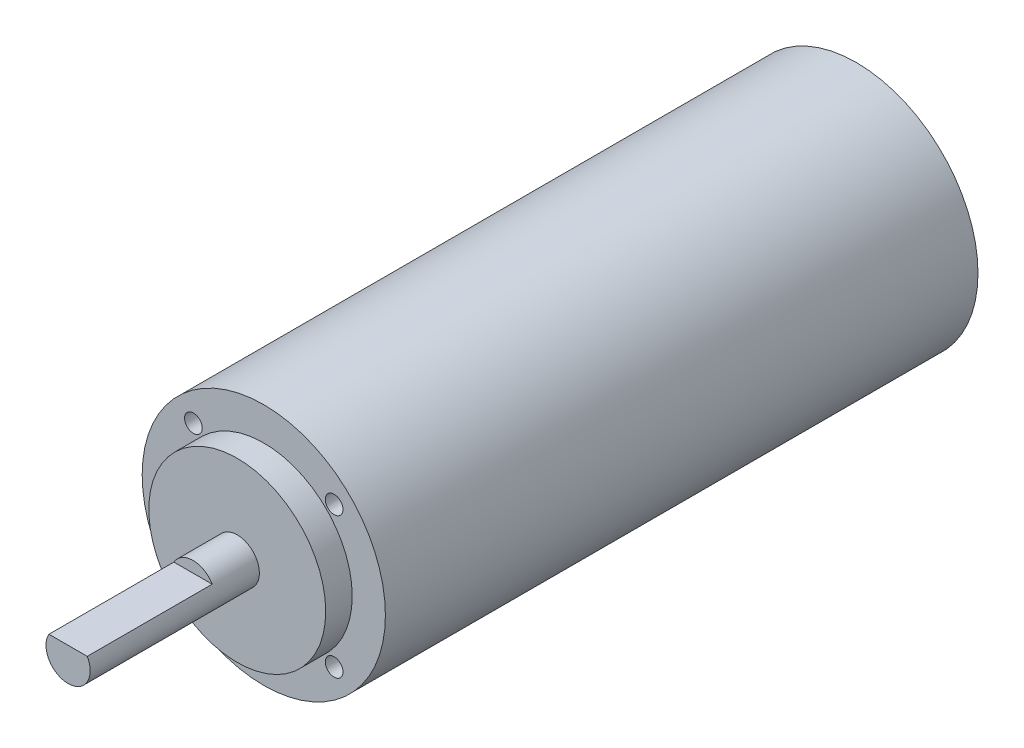
from build123d import *

# Parameters (mm, degrees)
CUT_EXTRUDE1_DEPTH              = 11.3
TAP_DRILL_FOR_M2X0_4_TAP1_D     = 1.6
TAP_DRILL_FOR_M2X0_4_TAP1_DEPTH = 4
TAP_DRILL_FOR_M2X0_4_TAP1_TIP   = 0.480688495


with BuildPart() as part:
    # Sketch4 → Revolve1 (revolve)
    with BuildSketch(Plane(origin=(0, 0, 0), x_dir=(0, 0, -1), z_dir=(1, 0, 0))):
        Polygon((0, 8), (0, 11), (21.4, 11), (53.6, 11), (53.6, 0), (0, 0), (-17.7, 0), (-17.7, 2), (-2.4, 2), (-2.4, 8), align=None)
    revolve(axis=Axis((0, 0, 0), (0, 0, -1)))

    # Sketch5 → Cut-Extrude1 (cut)
    with BuildSketch(Plane.XY.offset(17.7)):
        with BuildLine():
            Line((1.732050808, 1), (-1.732050808, 1))
            ThreePointArc((-1.732050808, 1), (-1, 1.732050808), (0, 2))
            ThreePointArc((0, 2), (1, 1.732050808), (1.732050808, 1))
        make_face()
    extrude(amount=-CUT_EXTRUDE1_DEPTH, mode=Mode.SUBTRACT)

    # Tap Drill for M2x0.4 Tap1
    with Locations(Plane.XY):
        with Locations((6.363961031, 6.363961031), (6.363961031, -6.363961031), (-6.363961031, -6.363961031), (-6.363961031, 6.363961031)):
            Hole(TAP_DRILL_FOR_M2X0_4_TAP1_D / 2, depth=TAP_DRILL_FOR_M2X0_4_TAP1_DEPTH)
            with Locations((0, 0, -(TAP_DRILL_FOR_M2X0_4_TAP1_DEPTH + TAP_DRILL_FOR_M2X0_4_TAP1_TIP / 2))):  # 118° drill point
                Cone(0, TAP_DRILL_FOR_M2X0_4_TAP1_D / 2, TAP_DRILL_FOR_M2X0_4_TAP1_TIP, mode=Mode.SUBTRACT)


solid = part.part
